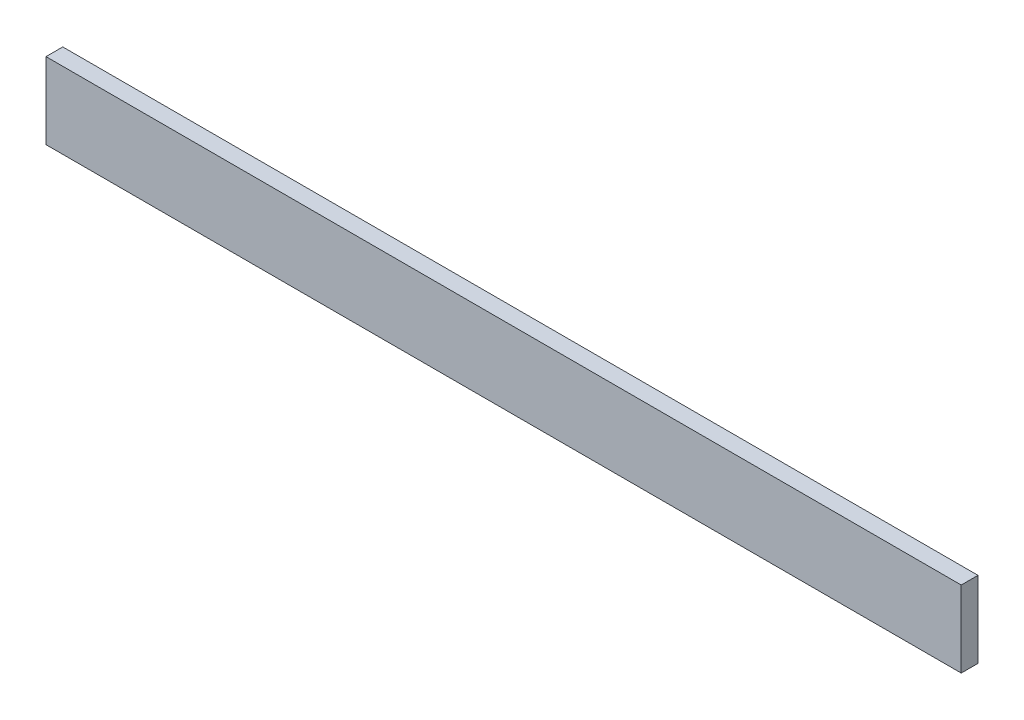
from build123d import *

# Parameters (mm, degrees)
SKETCH1_W           = 1200
SKETCH1_H           = 100
BOSS_EXTRUDE1_DEPTH = 22


with BuildPart() as part:
    # Sketch1 → Boss-Extrude1 (new body)
    with BuildSketch(Plane.XY):
        Rectangle(SKETCH1_W, SKETCH1_H)
    extrude(amount=BOSS_EXTRUDE1_DEPTH)


solid = part.part
